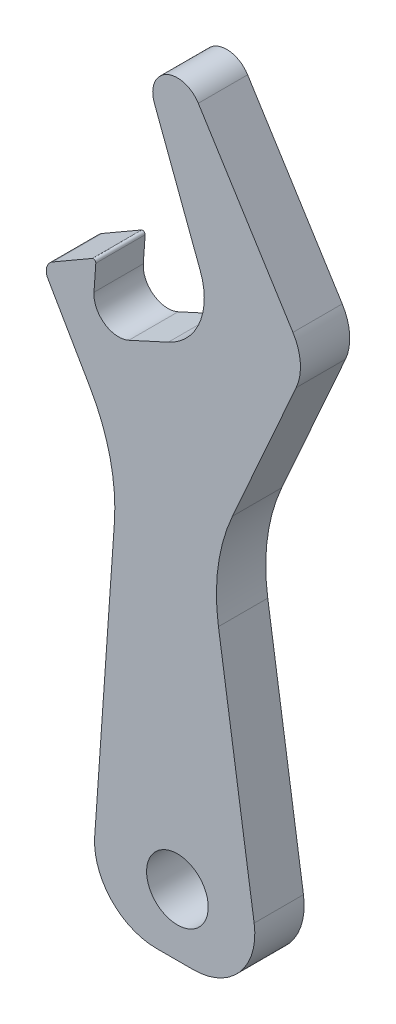
from build123d import *

# Parameters (mm, degrees)
SKIZZE1_R               = 2.5
LINEAR_AUSTRAGEN1_DEPTH = 4


with BuildPart() as part:
    # Skizze1 → Linear austragen1 (new body)
    with BuildSketch(Plane.XY):
        with BuildLine():
            Line((-1.720471048, -5), (1.279528952, -5))
            ThreePointArc((1.279528952, -5), (5.067353874, -3.263798762), (6.224608269, 0.739047056))
            Line((6.224608269, 0.739047056), (3.328540718, 20.117087516))
            ThreePointArc((3.328540718, 20.117087516), (3.300790208, 24.356992637), (4.460596804, 28.435278329))
            Line((4.460596804, 28.435278329), (9.633958573, 40.054839106))
            ThreePointArc((9.633958573, 40.054839106), (9.969901697, 41.962682181), (9.36998022, 43.804642334))
            Line((9.36998022, 43.804642334), (1.695101739, 56.061428328))
            ThreePointArc((1.695101739, 56.061428328), (-0.886899712, 56.792598366), (-1.872184322, 54.296490325))
            Line((-1.872184322, 54.296490325), (1.85912682, 44.36670191))
            ThreePointArc((1.85912682, 44.36670191), (1.800761722, 40.701037253), (-0.742535185, 38.060555344))
            Line((-0.742535185, 38.060555344), (-3.938539061, 36.599525001))
            ThreePointArc((-3.938539061, 36.599525001), (-5.909088644, 36.774512117), (-6.765186682, 38.5579869))
            Line((-6.765186682, 38.5579869), (-6.617488885, 40.670163795))
            ThreePointArc((-6.617488885, 40.670163795), (-6.711017842, 40.853724709), (-6.917001695, 40.85732017))
            Line((-6.917001695, 40.85732017), (-10.133974596, 39))
            ThreePointArc((-10.133974596, 39), (-10.599900423, 38.392793641), (-10.5, 37.633974596))
            Line((-10.5, 37.633974596), (-7.085329154, 31.719591199))
            ThreePointArc((-7.085329154, 31.719591199), (-5.460159239, 27.593857014), (-5.112249457, 23.173244093))
            Line((-5.112249457, 23.173244093), (-6.708291299, 0.348782369))
            ThreePointArc((-6.708291299, 0.348782369), (-5.377239556, -3.4099918), (-1.720471048, -5))
        make_face()
        Circle(SKIZZE1_R, mode=Mode.SUBTRACT)
    extrude(amount=LINEAR_AUSTRAGEN1_DEPTH)


solid = part.part
